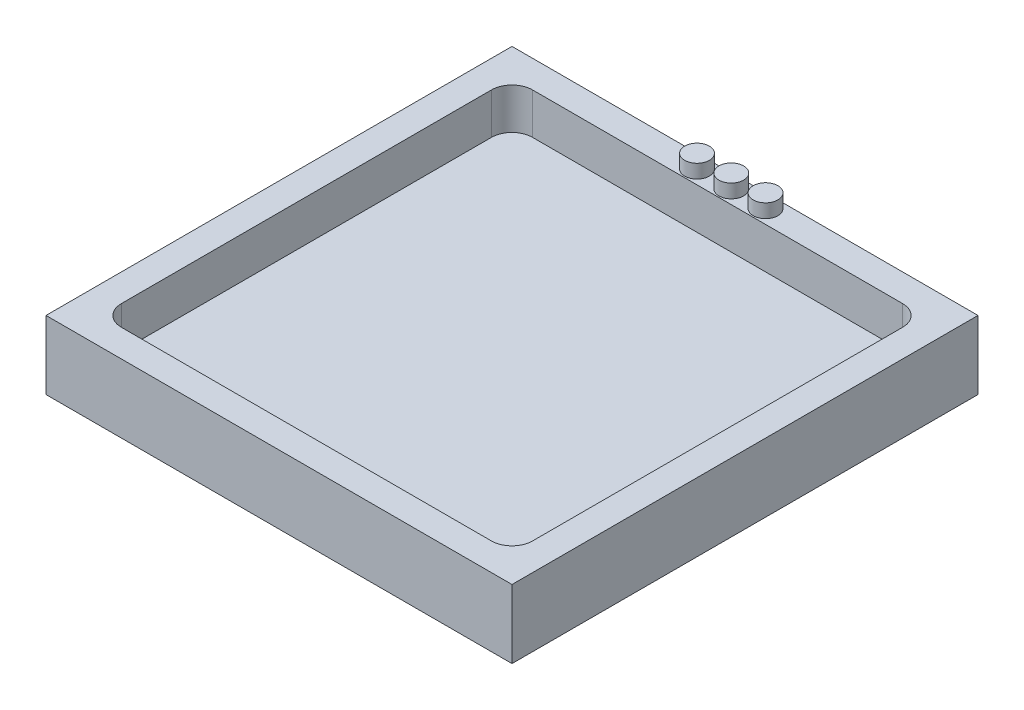
from build123d import *

# Parameters (mm, degrees)
SKETCH1_W           = 30
SKETCH1_H           = 30
BOSS_EXTRUDE2_DEPTH = 2
SKETCH1_6_W         = 34
SKETCH1_6_H         = 34
SKETCH1_6_W_2       = 30
SKETCH1_6_H_2       = 30
BOSS_EXTRUDE3_DEPTH = 5
FILLET1_R           = 1.5
SKETCH2_R           = 0.9
BOSS_EXTRUDE4_DEPTH = 1


with BuildPart() as part:
    # Sketch1 → Boss-Extrude2 (new body)
    with BuildSketch(Plane(origin=(0, 0, 0), x_dir=(1, 0, 0), z_dir=(0, 1, 0))):
        Rectangle(SKETCH1_W, SKETCH1_H)
    extrude(amount=BOSS_EXTRUDE2_DEPTH)

    # Sketch1_6 → Boss-Extrude3 (add)
    with BuildSketch(Plane(origin=(0, 0, 0), x_dir=(1, 0, 0), z_dir=(0, 1, 0))):
        Rectangle(SKETCH1_6_W, SKETCH1_6_H)
        Rectangle(SKETCH1_6_W_2, SKETCH1_6_H_2, mode=Mode.SUBTRACT)
    extrude(amount=BOSS_EXTRUDE3_DEPTH)

    # Fillet1
    fillet1_edges = [part.edges().sort_by_distance(p)[0] for p in [
        (15, 3.5, -15),
        (-15, 3.5, -15),
        (-15, 3.5, 15),
        (15, 3.5, 15),
    ]]
    fillet(fillet1_edges, radius=FILLET1_R)

    # Sketch2 → Boss-Extrude4 (add)
    with BuildSketch(Plane(origin=(0, 5, 0), x_dir=(1, 0, 0), z_dir=(0, 1, 0))):
        with Locations((0, 16)):
            Circle(SKETCH2_R)
        with Locations((2.5, 16)):
            Circle(SKETCH2_R)
        with Locations((-2.5, 16)):
            Circle(SKETCH2_R)
    extrude(amount=BOSS_EXTRUDE4_DEPTH)


solid = part.part
